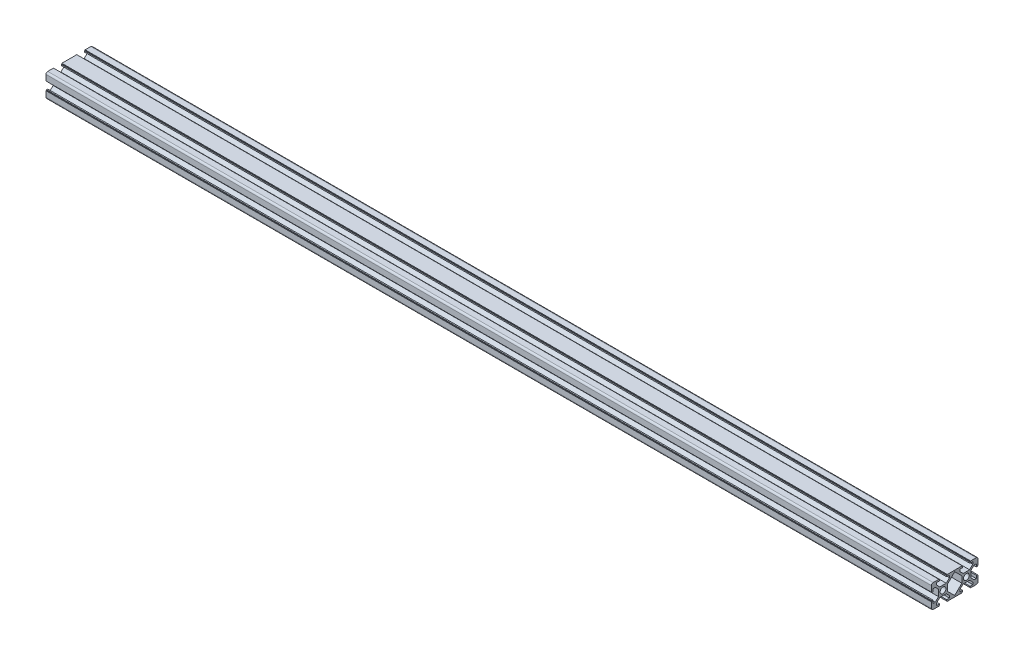
from build123d import *

# Parameters (mm, degrees)
SKETCH1_R                = 2.5
F_20_X_40_X_T1_5_1_DEPTH = 760


with BuildPart() as part:
    # Sketch1 → 铝型材 20 X 40 X T1.5(1) (new body)
    with BuildSketch(Plane.YZ):
        with BuildLine():
            Line((-3.6, 10), (-3.6, 9.5))
            Line((-3.6, 9.5), (-3.1, 9.5))
            Line((-3.1, 9.5), (-3.1, 8.5))
            Line((-3.1, 8.5), (-5.5, 8.5))
            Line((-5.5, 8.5), (-5.5, 6.65))
            Line((-5.5, 6.65), (-2.75, 3.9))
            Line((-2.75, 3.9), (2.75, 3.9))
            Line((2.75, 3.9), (5.5, 6.65))
            Line((5.5, 6.65), (5.5, 8.5))
            Line((5.5, 8.5), (3.1, 8.5))
            Line((3.1, 8.5), (3.1, 9.5))
            Line((3.1, 9.5), (3.6, 9.5))
            Line((3.6, 9.5), (3.6, 10))
            Line((3.6, 10), (8.5, 10))
            ThreePointArc((8.5, 10), (9.560660172, 9.560660172), (10, 8.5))
            Line((10, 8.5), (10, 3.6))
            Line((10, 3.6), (9.5, 3.6))
            Line((9.5, 3.6), (9.5, 3.1))
            Line((9.5, 3.1), (8.5, 3.1))
            Line((8.5, 3.1), (8.5, 5.5))
            Line((8.5, 5.5), (6.65, 5.5))
            Line((6.65, 5.5), (3.9, 2.75))
            Line((3.9, 2.75), (3.9, -2.75))
            Line((3.9, -2.75), (6.65, -5.5))
            Line((6.65, -5.5), (8.5, -5.5))
            Line((8.5, -5.5), (8.5, -3.1))
            Line((8.5, -3.1), (9.5, -3.1))
            Line((9.5, -3.1), (9.5, -3.6))
            Line((9.5, -3.6), (10, -3.6))
            Line((10, -3.6), (10, -16.4))
            Line((10, -16.4), (9.5, -16.4))
            Line((9.5, -16.4), (9.5, -16.9))
            Line((9.5, -16.9), (8.5, -16.9))
            Line((8.5, -16.9), (8.5, -14.5))
            Line((8.5, -14.5), (6.65, -14.5))
            Line((6.65, -14.5), (3.9, -17.25))
            Line((3.9, -17.25), (3.9, -22.75))
            Line((3.9, -22.75), (6.65, -25.5))
            Line((6.65, -25.5), (8.5, -25.5))
            Line((8.5, -25.5), (8.5, -23.1))
            Line((8.5, -23.1), (9.5, -23.1))
            Line((9.5, -23.1), (9.5, -23.6))
            Line((9.5, -23.6), (10, -23.6))
            Line((10, -23.6), (10, -28.5))
            ThreePointArc((10, -28.5), (9.560660172, -29.560660172), (8.5, -30))
            Line((8.5, -30), (3.6, -30))
            Line((3.6, -30), (3.6, -29.5))
            Line((3.6, -29.5), (3.1, -29.5))
            Line((3.1, -29.5), (3.1, -28.5))
            Line((3.1, -28.5), (5.5, -28.5))
            Line((5.5, -28.5), (5.5, -26.65))
            Line((5.5, -26.65), (2.75, -23.9))
            Line((2.75, -23.9), (-2.75, -23.9))
            Line((-2.75, -23.9), (-5.5, -26.65))
            Line((-5.5, -26.65), (-5.5, -28.5))
            Line((-5.5, -28.5), (-3.1, -28.5))
            Line((-3.1, -28.5), (-3.1, -29.5))
            Line((-3.1, -29.5), (-3.6, -29.5))
            Line((-3.6, -29.5), (-3.6, -30))
            Line((-3.6, -30), (-8.5, -30))
            ThreePointArc((-8.5, -30), (-9.560660172, -29.560660172), (-10, -28.5))
            Line((-10, -28.5), (-10, -23.6))
            Line((-10, -23.6), (-9.5, -23.6))
            Line((-9.5, -23.6), (-9.5, -23.1))
            Line((-9.5, -23.1), (-8.5, -23.1))
            Line((-8.5, -23.1), (-8.5, -25.5))
            Line((-8.5, -25.5), (-6.65, -25.5))
            Line((-6.65, -25.5), (-3.9, -22.75))
            Line((-3.9, -22.75), (-3.9, -17.25))
            Line((-3.9, -17.25), (-6.65, -14.5))
            Line((-6.65, -14.5), (-8.5, -14.5))
            Line((-8.5, -14.5), (-8.5, -16.9))
            Line((-8.5, -16.9), (-9.5, -16.9))
            Line((-9.5, -16.9), (-9.5, -16.4))
            Line((-9.5, -16.4), (-10, -16.4))
            Line((-10, -16.4), (-10, -3.6))
            Line((-10, -3.6), (-9.5, -3.6))
            Line((-9.5, -3.6), (-9.5, -3.1))
            Line((-9.5, -3.1), (-8.5, -3.1))
            Line((-8.5, -3.1), (-8.5, -5.5))
            Line((-8.5, -5.5), (-6.65, -5.5))
            Line((-6.65, -5.5), (-3.9, -2.75))
            Line((-3.9, -2.75), (-3.9, 2.75))
            Line((-3.9, 2.75), (-6.65, 5.5))
            Line((-6.65, 5.5), (-8.5, 5.5))
            Line((-8.5, 5.5), (-8.5, 3.1))
            Line((-8.5, 3.1), (-9.5, 3.1))
            Line((-9.5, 3.1), (-9.5, 3.6))
            Line((-9.5, 3.6), (-10, 3.6))
            Line((-10, 3.6), (-10, 8.5))
            ThreePointArc((-10, 8.5), (-9.560660172, 9.560660172), (-8.5, 10))
            Line((-8.5, 10), (-3.6, 10))
        make_face()
        Circle(SKETCH1_R, mode=Mode.SUBTRACT)
        with Locations((0, -20)):
            Circle(SKETCH1_R, mode=Mode.SUBTRACT)
        Polygon((8.85, -10), (2.75, -3.9), (-2.75, -3.9), (-8.85, -10), (-2.75, -16.1), (2.75, -16.1), align=None, mode=Mode.SUBTRACT)
    extrude(amount=F_20_X_40_X_T1_5_1_DEPTH)


solid = part.part
